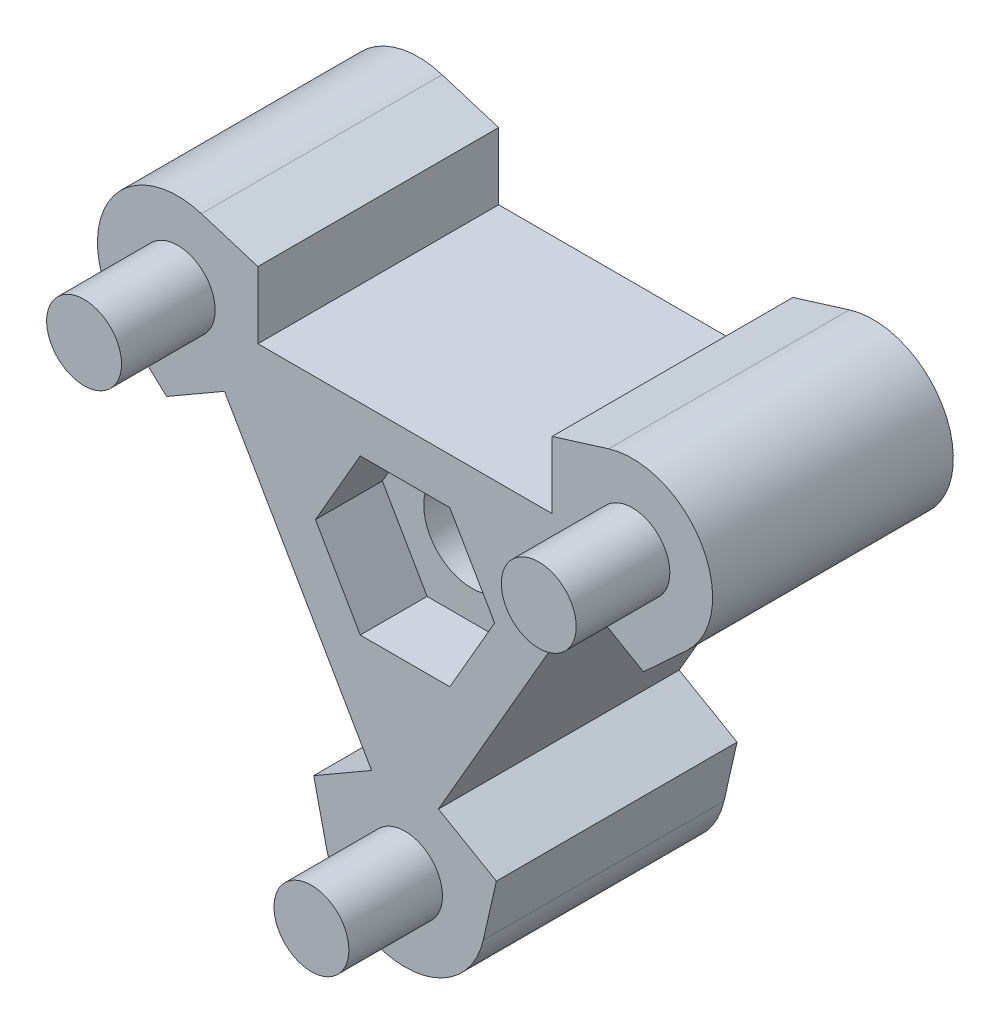
from build123d import *

# Parameters (mm, degrees)
EXTRUDE_1_DEPTH     = 4
SKETCH_2_R          = 1.4
EXTRUDE_2_DEPTH     = 3.5
CUT_EXTRUDE_1_DEPTH = 2.5
SKETCH_6_R          = 1.8
CUT_EXTRUDE_2_DEPTH = 8.5
SKETCH_7_R          = 1.8
EXTRUDE_3_DEPTH     = 5


with BuildPart() as part:
    # ｽｹｯﾁ1 → ﾎﾞｽ - 押し出し1 (new body)
    with BuildSketch(Plane.XY):
        with BuildLine():
            Line((-6.75, 2.453738644), (-8.915063509, 1.203738644))
            Line((-8.915063509, 1.203738644), (-10.537880917, 2.705877559))
            ThreePointArc((-10.537880917, 2.705877559), (-11.098076211, 6.407477288), (-7.612299165, 7.773133797))
            Line((-7.612299165, 7.773133797), (-5.5, 7.118802154))
            Line((-5.5, 7.118802154), (-5.5, 4.618802154))
            Line((-5.5, 4.618802154), (5.5, 4.618802154))
            Line((5.5, 4.618802154), (5.5, 7.118802154))
            Line((5.5, 7.118802154), (7.612299165, 7.773133797))
            ThreePointArc((7.612299165, 7.773133797), (11.098076211, 6.407477288), (10.537880917, 2.705877559))
            Line((10.537880917, 2.705877559), (8.915063509, 1.203738644))
            Line((8.915063509, 1.203738644), (6.75, 2.453738644))
            Line((6.75, 2.453738644), (1.25, -7.072540798))
            Line((1.25, -7.072540798), (3.415063509, -8.322540798))
            Line((3.415063509, -8.322540798), (2.925581753, -10.479011356))
            ThreePointArc((2.925581753, -10.479011356), (0, -12.814954576), (-2.925581753, -10.479011356))
            Line((-2.925581753, -10.479011356), (-3.415063509, -8.322540798))
            Line((-3.415063509, -8.322540798), (-1.25, -7.072540798))
            Line((-1.25, -7.072540798), (-6.75, 2.453738644))
        make_face()
    extrude(amount=EXTRUDE_1_DEPTH)

    # ｽｹｯﾁ2 → ﾎﾞｽ - 押し出し2 (add)
    with BuildSketch(Plane.XY.offset(4)):
        with Locations((-8.5, 4.907477288)):
            Circle(SKETCH_2_R)
        with Locations((0, -9.814954576)):
            Circle(SKETCH_2_R)
        with Locations((8.5, 4.907477288)):
            Circle(SKETCH_2_R)
    extrude(amount=EXTRUDE_2_DEPTH)

    # ｽｹｯﾁ4 → ｶｯﾄ - 押し出し1 (cut)
    with BuildSketch(Plane.XY.offset(4)):
        Polygon((-1.674315781, -2.9), (1.674315781, -2.9), (3.348631561, 0), (1.674315781, 2.9), (-1.674315781, 2.9), (-3.348631561, 0), align=None)
    extrude(amount=-CUT_EXTRUDE_1_DEPTH, mode=Mode.SUBTRACT)

    # ｽｹｯﾁ6 → ｶｯﾄ - 押し出し2 (cut, through all)
    with BuildSketch(Plane(origin=(0, 0, 0), x_dir=(-1, 0, 0), z_dir=(0, 0, -1))):
        Circle(SKETCH_6_R)
    extrude(amount=-CUT_EXTRUDE_2_DEPTH, mode=Mode.SUBTRACT)

    # ｽｹｯﾁ7 → ﾎﾞｽ - 押し出し3 (add)
    with BuildSketch(Plane(origin=(0, 0, 0), x_dir=(-1, 0, 0), z_dir=(0, 0, -1))):
        with BuildLine():
            Line((-8.915063509, 1.203738644), (-6.75, 2.453738644))
            Line((-6.75, 2.453738644), (-1.25, -7.072540798))
            Line((-1.25, -7.072540798), (-3.415063509, -8.322540798))
            Line((-3.415063509, -8.322540798), (-2.925581753, -10.479011356))
            ThreePointArc((-2.925581753, -10.479011356), (0, -12.814954576), (2.925581753, -10.479011356))
            Line((2.925581753, -10.479011356), (3.415063509, -8.322540798))
            Line((3.415063509, -8.322540798), (1.25, -7.072540798))
            Line((1.25, -7.072540798), (6.75, 2.453738644))
            Line((6.75, 2.453738644), (8.915063509, 1.203738644))
            Line((8.915063509, 1.203738644), (10.537880917, 2.705877559))
            ThreePointArc((10.537880917, 2.705877559), (11.098076211, 6.407477288), (7.612299165, 7.773133797))
            Line((7.612299165, 7.773133797), (5.5, 7.118802154))
            Line((5.5, 7.118802154), (5.5, 4.618802154))
            Line((5.5, 4.618802154), (-5.5, 4.618802154))
            Line((-5.5, 4.618802154), (-5.5, 7.118802154))
            Line((-5.5, 7.118802154), (-7.612299165, 7.773133797))
            ThreePointArc((-7.612299165, 7.773133797), (-11.098076211, 6.407477288), (-10.537880917, 2.705877559))
            Line((-10.537880917, 2.705877559), (-8.915063509, 1.203738644))
        make_face()
        Circle(SKETCH_7_R, mode=Mode.SUBTRACT)
    extrude(amount=EXTRUDE_3_DEPTH)


solid = part.part
